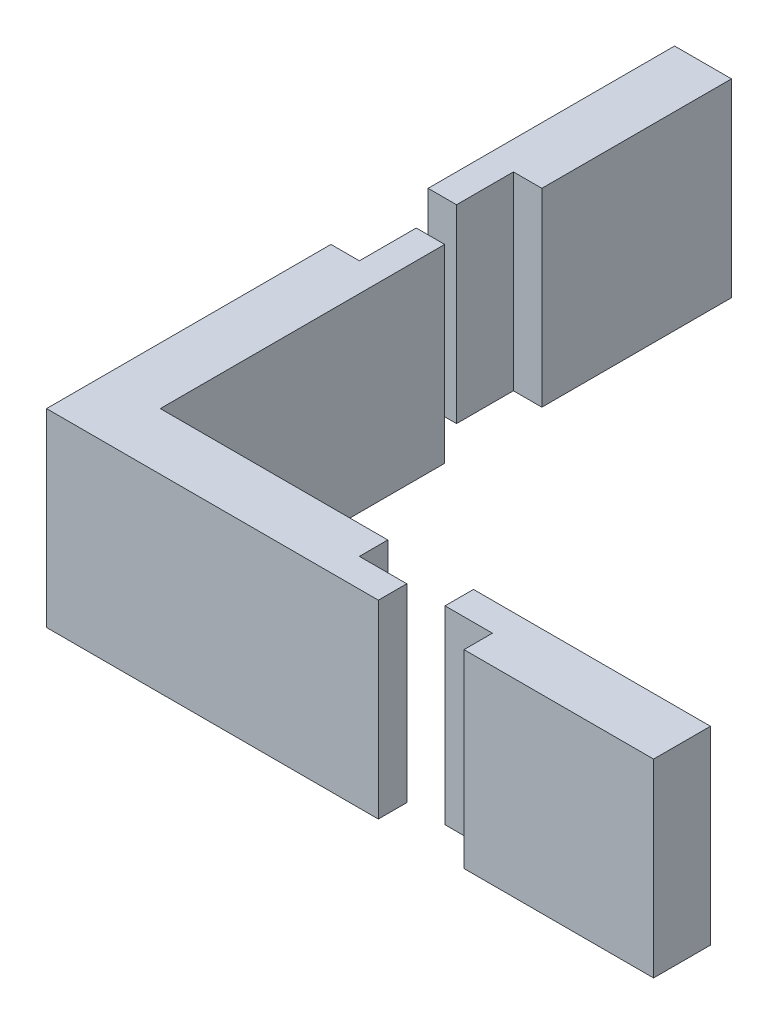
from build123d import *

# Parameters (mm, degrees)
SKETCH1_W           = 1.5
SKETCH1_H           = 3
SKETCH1_W_2         = 3
SKETCH1_H_2         = 15
SKETCH1_W_3         = 2.5
SKETCH1_H_3         = 1.5
BOSS_EXTRUDE2_DEPTH = 10


with BuildPart() as part:
    # Sketch1 → Boss-Extrude2 (new body)
    with BuildSketch(Plane(origin=(0, 0, 0), x_dir=(1, 0, 0), z_dir=(0, 1, 0))):
        Polygon((-1.5, 15.625086096), (0, 15.625086096), (1.5, 15.625086096), (1.5, 25.625086096), (-1.5, 25.625086096), align=None)
        with Locations((-0.75, 14.125086096)):
            Rectangle(SKETCH1_W, SKETCH1_H)
        with Locations((0.75, 9)):
            Rectangle(SKETCH1_W, SKETCH1_H)
        Rectangle(SKETCH1_W_2, SKETCH1_H_2)
        Polygon((1.5, -4.5), (1.5, -7.5), (13.5, -7.5), (13.5, -6), (13.5, -4.5), align=None)
        with Locations((19.267750949, -5.25)):
            Rectangle(SKETCH1_W_3, SKETCH1_H_3)
        Polygon((20.517750949, -4.5), (20.517750949, -6), (20.517750949, -7.5), (30.517750949, -7.5), (30.517750949, -4.5), align=None)
        with Locations((14.75, -6.75)):
            Rectangle(SKETCH1_W_3, SKETCH1_H_3)
    extrude(amount=BOSS_EXTRUDE2_DEPTH)


solid = part.part
